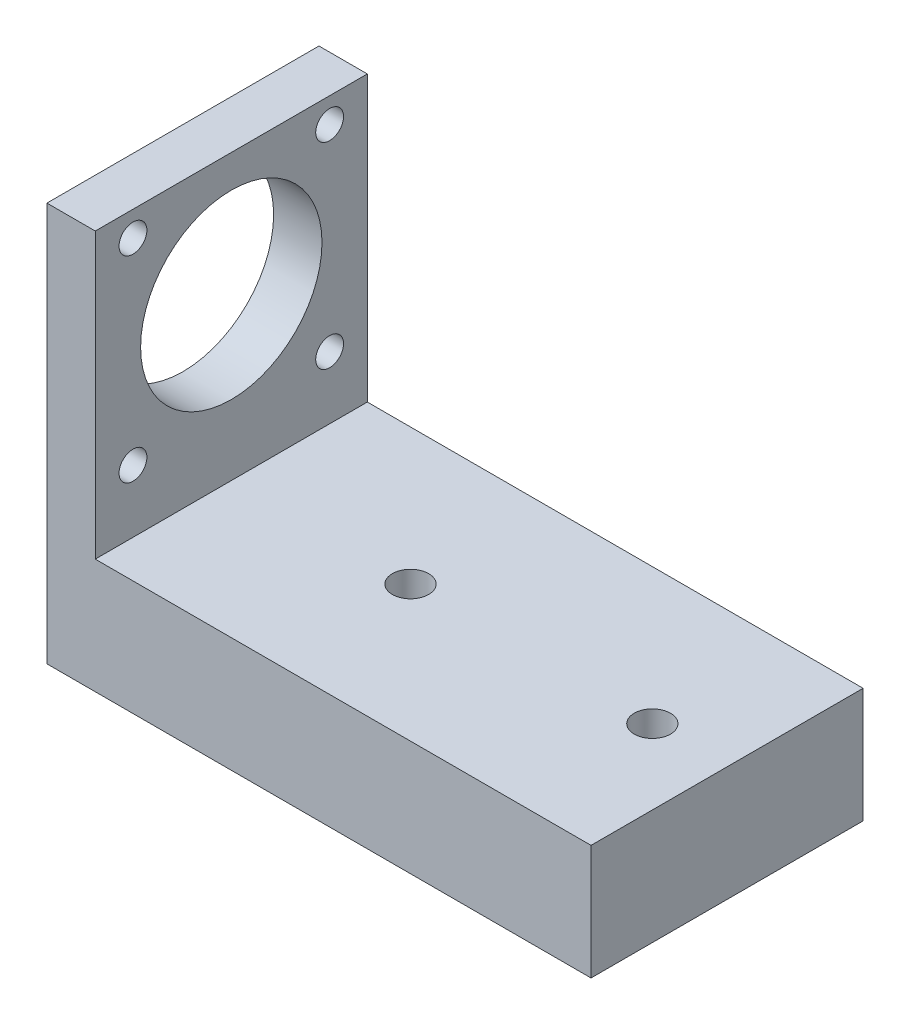
from build123d import *

# Parameters (mm, degrees)
SKETCH1_W           = 90
SKETCH1_H           = 45
BOSS_EXTRUDE1_DEPTH = 5
SKETCH2_W           = 8
SKETCH2_H           = 45
BOSS_EXTRUDE2_DEPTH = 66
SKETCH4_W           = 82
SKETCH4_H           = 45
BOSS_EXTRUDE3_DEPTH = 19
SKETCH5_R           = 15
SKETCH5_R_2         = 2.3
CUT_EXTRUDE1_DEPTH  = 55
SKETCH6_R           = 3
CUT_EXTRUDE2_DEPTH  = 55


with BuildPart() as part:
    # Sketch1 → Boss-Extrude1 (new body)
    with BuildSketch(Plane(origin=(0, 0, 0), x_dir=(1, 0, 0), z_dir=(0, 1, 0))):
        Rectangle(SKETCH1_W, SKETCH1_H)
    extrude(amount=BOSS_EXTRUDE1_DEPTH)

    # Sketch2 → Boss-Extrude2 (add)
    with BuildSketch(Plane(origin=(0, 0, 0), x_dir=(1, 0, 0), z_dir=(0, 1, 0))):
        with Locations((-41, 0)):
            Rectangle(SKETCH2_W, SKETCH2_H)
    extrude(amount=BOSS_EXTRUDE2_DEPTH)

    # Sketch4 → Boss-Extrude3 (add)
    with BuildSketch(Plane(origin=(0, 0, 0), x_dir=(1, 0, 0), z_dir=(0, 1, 0))):
        with Locations((4, 0)):
            Rectangle(SKETCH4_W, SKETCH4_H)
    extrude(amount=BOSS_EXTRUDE3_DEPTH)

    # Sketch5 → Cut-Extrude1 (cut)
    with BuildSketch(Plane(origin=(0, 0, 0), x_dir=(0, 0, -1), z_dir=(1, 0, 0))):
        with Locations((0, 45.6)):
            Circle(SKETCH5_R)
        with Locations((16.263455967, 61.863455967)):
            Circle(SKETCH5_R_2)
        with Locations((16.263455967, 29.336544033)):
            Circle(SKETCH5_R_2)
        with Locations((-16.263455967, 29.336544033)):
            Circle(SKETCH5_R_2)
        with Locations((-16.263455967, 61.863455967)):
            Circle(SKETCH5_R_2)
    extrude(amount=-CUT_EXTRUDE1_DEPTH, mode=Mode.SUBTRACT)

    # Sketch6 → Cut-Extrude2 (cut)
    with BuildSketch(Plane(origin=(0, 0, 0), x_dir=(1, 0, 0), z_dir=(0, 1, 0))):
        with Locations((32.641263943, 0)):
            Circle(SKETCH6_R)
        with Locations((-7.358736057, 0)):
            Circle(SKETCH6_R)
    extrude(amount=CUT_EXTRUDE2_DEPTH, mode=Mode.SUBTRACT)


solid = part.part
